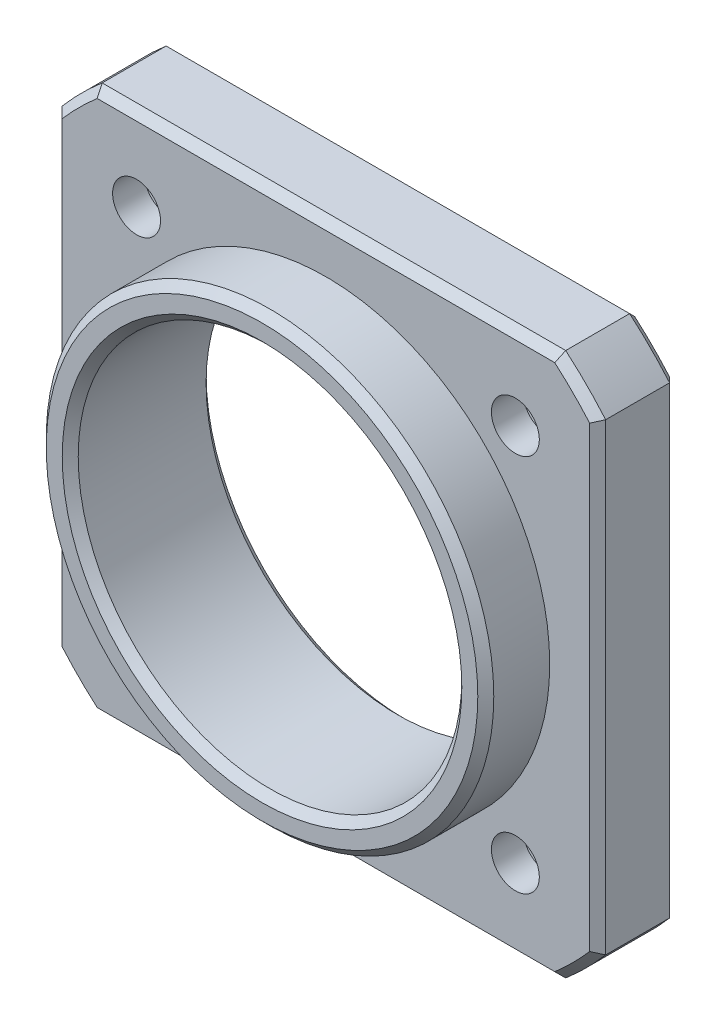
from build123d import *

# Parameters (mm, degrees)
SKETCH1_R           = 1.5
SKETCH1_R_2         = 12
BOSS_EXTRUDE1_DEPTH = 9
SKETCH2_R           = 14
CUT_EXTRUDE1_DEPTH  = 4
SKETCH3_R           = 4
CUT_EXTRUDE2_DEPTH  = 3
CHAMFER1_SIZE       = 0.5
CHAMFER2_SIZE       = 0.5


with BuildPart() as part:
    # Sketch1 → Boss-Extrude1 (new body)
    with BuildSketch(Plane.XY):
        with BuildLine():
            Line((-14.5, 17), (14.5, 17))
            ThreePointArc((14.5, 17), (15.799525309, 15.799525309), (17, 14.5))
            Line((17, 14.5), (17, -14.5))
            ThreePointArc((17, -14.5), (15.799525309, -15.799525309), (14.5, -17))
            Line((14.5, -17), (-14.5, -17))
            ThreePointArc((-14.5, -17), (-15.799525309, -15.799525309), (-17, -14.5))
            Line((-17, -14.5), (-17, 14.5))
            ThreePointArc((-17, 14.5), (-15.799525309, 15.799525309), (-14.5, 17))
        make_face()
        with Locations((-11.85, 11.85)):
            Circle(SKETCH1_R, mode=Mode.SUBTRACT)
        with Locations((11.85, 11.85)):
            Circle(SKETCH1_R, mode=Mode.SUBTRACT)
        with Locations((11.85, -11.85)):
            Circle(SKETCH1_R, mode=Mode.SUBTRACT)
        with Locations((-11.85, -11.85)):
            Circle(SKETCH1_R, mode=Mode.SUBTRACT)
        Circle(SKETCH1_R_2, mode=Mode.SUBTRACT)
    extrude(amount=BOSS_EXTRUDE1_DEPTH)

    # Sketch2 → Cut-Extrude1 (cut)
    with BuildSketch(Plane.XY.offset(9)):
        with BuildLine():
            Line((-14.5, 17), (14.5, 17))
            ThreePointArc((14.5, 17), (15.799525309, 15.799525309), (17, 14.5))
            Line((17, 14.5), (17, -14.5))
            ThreePointArc((17, -14.5), (15.799525309, -15.799525309), (14.5, -17))
            Line((14.5, -17), (-14.5, -17))
            ThreePointArc((-14.5, -17), (-15.799525309, -15.799525309), (-17, -14.5))
            Line((-17, -14.5), (-17, 14.5))
            ThreePointArc((-17, 14.5), (-15.799525309, 15.799525309), (-14.5, 17))
        make_face()
        Circle(SKETCH2_R, mode=Mode.SUBTRACT)
    extrude(amount=-CUT_EXTRUDE1_DEPTH, mode=Mode.SUBTRACT)

    # Sketch3 → Cut-Extrude2 (cut)
    with BuildSketch(Plane(origin=(0, 0, 0), x_dir=(-1, 0, 0), z_dir=(0, 0, -1))):
        with Locations((-11.85, 11.85)):
            Circle(SKETCH3_R)
        with Locations((11.85, 11.85)):
            Circle(SKETCH3_R)
        with Locations((11.85, -11.85)):
            Circle(SKETCH3_R)
        with Locations((-11.85, -11.85)):
            Circle(SKETCH3_R)
    extrude(amount=-CUT_EXTRUDE2_DEPTH, mode=Mode.SUBTRACT)

    # Chamfer1
    chamfer1_edges = [part.edges().sort_by_distance(p)[0] for p in [
        (-17, 0, 0),
        (-15.799525309, 15.799525309, 0),
        (-15.799525309, 15.799525309, 5),
        (0, 17, 5),
        (15.799525309, 15.799525309, 5),
        (17, 0, 5),
        (15.799525309, -15.799525309, 5),
        (0, -17, 5),
        (-15.799525309, -15.799525309, 5),
        (-17, 0, 5),
        (0, 17, 0),
        (15.799525309, 15.799525309, 0),
        (17, 0, 0),
        (15.799525309, -15.799525309, 0),
        (0, -17, 0),
        (-15.799525309, -15.799525309, 0),
    ]]
    chamfer(chamfer1_edges, length=CHAMFER1_SIZE)

    # Chamfer2
    chamfer2_edges = [part.edges().sort_by_distance(p)[0] for p in [
        (-12, 0, 0),
        (-12, 0, 9),
        (-14, 0, 9),
    ]]
    chamfer(chamfer2_edges, length=CHAMFER2_SIZE)


solid = part.part
